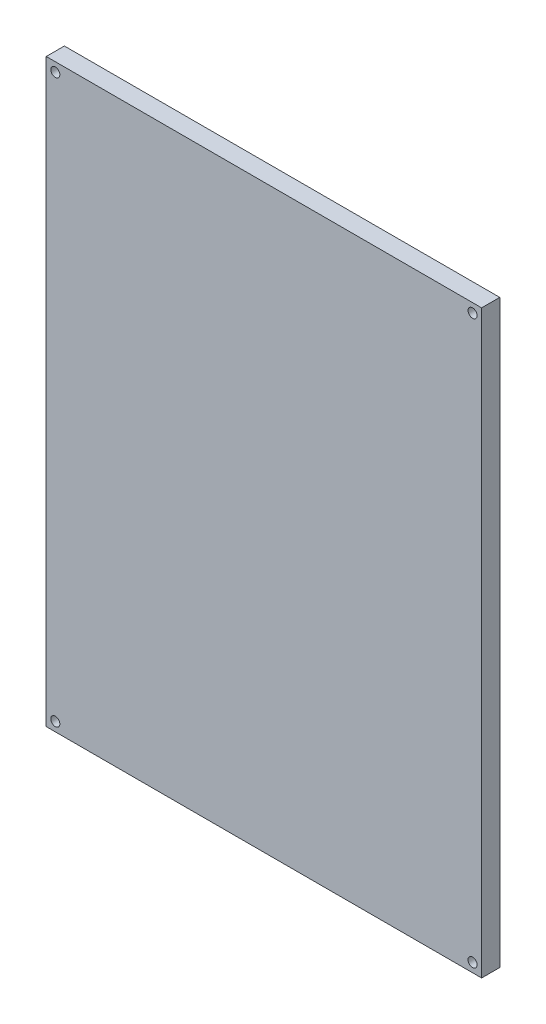
from build123d import *

# Parameters (mm, degrees)
SKETCH1_W           = 240.15
SKETCH1_H           = 320.13
SKETCH1_R           = 2.5
BOSS_EXTRUDE1_DEPTH = 10


with BuildPart() as part:
    # Sketch1 → Boss-Extrude1 (new body)
    with BuildSketch(Plane.XY):
        Rectangle(SKETCH1_W, SKETCH1_H)
        with Locations((-115.075, 155.065)):
            Circle(SKETCH1_R, mode=Mode.SUBTRACT)
        with Locations((115.075, 155.065)):
            Circle(SKETCH1_R, mode=Mode.SUBTRACT)
        with Locations((-115.075, -155.065)):
            Circle(SKETCH1_R, mode=Mode.SUBTRACT)
        with Locations((115.075, -155.065)):
            Circle(SKETCH1_R, mode=Mode.SUBTRACT)
    extrude(amount=BOSS_EXTRUDE1_DEPTH)


solid = part.part
